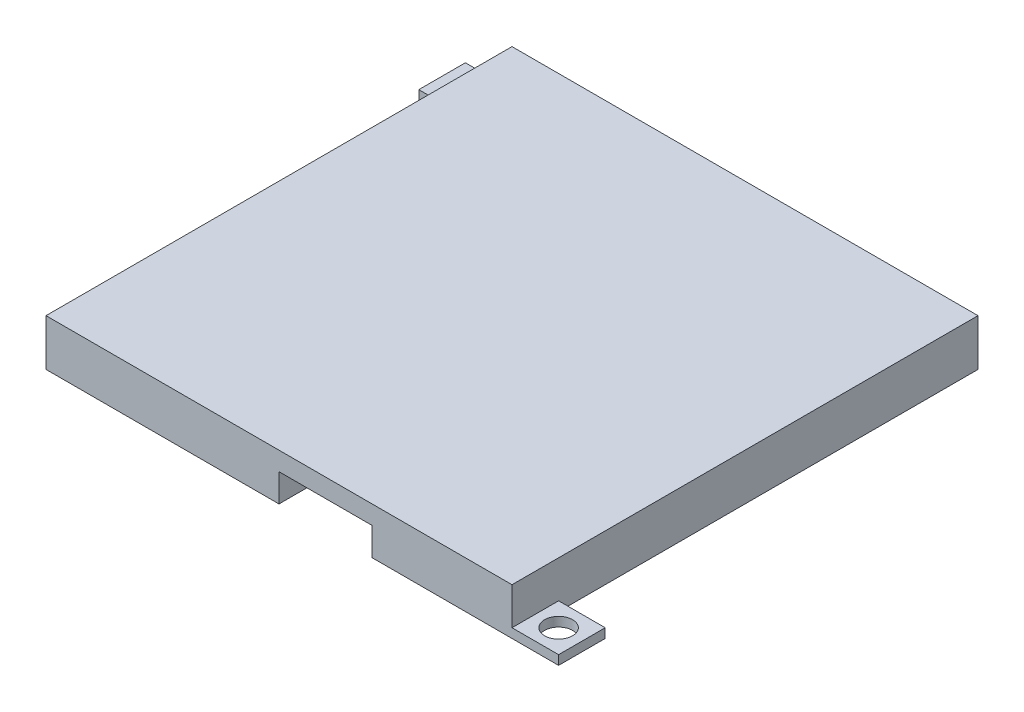
from build123d import *

# Parameters (mm, degrees)
SKETCH1_W           = 50
SKETCH1_H           = 50
BOSS_EXTRUDE2_DEPTH = 5
SKETCH2_W           = 40
SKETCH2_H           = 40
CUT_EXTRUDE1_DEPTH  = 3
SKETCH3_W           = 5
SKETCH3_H           = 5
BOSS_EXTRUDE3_DEPTH = 1
SKETCH4_R           = 1.5
CUT_EXTRUDE2_DEPTH  = 1
SKETCH6_W           = 10
SKETCH6_H           = 3
CUT_EXTRUDE3_DEPTH  = 10


with BuildPart() as part:
    # Sketch1 → Boss-Extrude2 (new body)
    with BuildSketch(Plane(origin=(0, 0, 0), x_dir=(1, 0, 0), z_dir=(0, 1, 0))):
        Rectangle(SKETCH1_W, SKETCH1_H)
    extrude(amount=BOSS_EXTRUDE2_DEPTH)

    # Sketch2 → Cut-Extrude1 (cut)
    with BuildSketch(Plane(origin=(0, 0, 0), x_dir=(-1, 0, 0), z_dir=(0, -1, 0))):
        Rectangle(SKETCH2_W, SKETCH2_H)
    extrude(amount=-CUT_EXTRUDE1_DEPTH, mode=Mode.SUBTRACT)

    # Sketch3 → Boss-Extrude3 (add)
    with BuildSketch(Plane(origin=(0, 0, 0), x_dir=(-1, 0, 0), z_dir=(0, -1, 0))):
        with Locations((27.5, 22.5)):
            Rectangle(SKETCH3_W, SKETCH3_H)
        with Locations((-27.5, -22.5)):
            Rectangle(SKETCH3_W, SKETCH3_H)
    extrude(amount=-BOSS_EXTRUDE3_DEPTH)

    # Sketch4 → Cut-Extrude2 (cut)
    with BuildSketch(Plane(origin=(0, 1, 0), x_dir=(1, 0, 0), z_dir=(0, 1, 0))):
        with Locations(Location((-27.5, 22.5, 0), (0, 0, 270))):  # turned: the seam where the file's is
            Circle(SKETCH4_R)
        with Locations(Location((27.5, -22.5, 0), (0, 0, 270))):  # turned: the seam where the file's is
            Circle(SKETCH4_R)
    extrude(amount=-CUT_EXTRUDE2_DEPTH, mode=Mode.SUBTRACT)

    # Sketch6 → Cut-Extrude3 (cut)
    with BuildSketch(Plane.XY.offset(25)):
        with Locations((5, 1.5)):
            Rectangle(SKETCH6_W, SKETCH6_H)
    extrude(amount=-CUT_EXTRUDE3_DEPTH, mode=Mode.SUBTRACT)


solid = part.part
